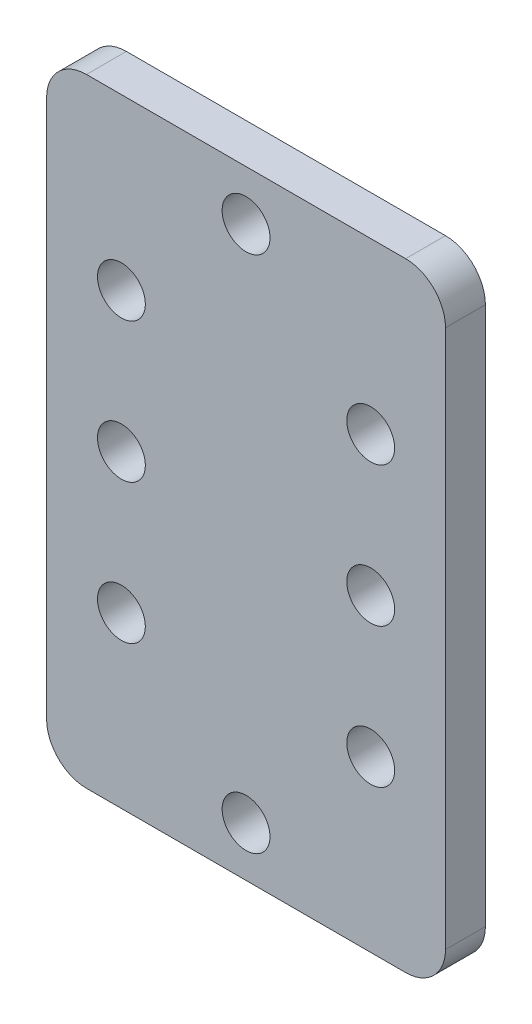
from build123d import *

# Parameters (mm, degrees)
SKETCH1_W           = 25.4
SKETCH1_H           = 39.37
SKETCH1_R           = 1.524
BOSS_EXTRUDE1_DEPTH = 2.54
FILLET1_R           = 2.54


with BuildPart() as part:
    # Sketch1 → Boss-Extrude1 (new body)
    with BuildSketch(Plane.XY):
        with Locations((12.7, -19.685)):
            Rectangle(SKETCH1_W, SKETCH1_H)
        with Locations((4.7625, -19.685)):
            Circle(SKETCH1_R, mode=Mode.SUBTRACT)
        with Locations((20.6375, -19.685)):
            Circle(SKETCH1_R, mode=Mode.SUBTRACT)
        with Locations((4.7625, -10.795)):
            Circle(SKETCH1_R, mode=Mode.SUBTRACT)
        with Locations((20.6375, -10.795)):
            Circle(SKETCH1_R, mode=Mode.SUBTRACT)
        with Locations((4.7625, -28.575)):
            Circle(SKETCH1_R, mode=Mode.SUBTRACT)
        with Locations((20.6375, -28.575)):
            Circle(SKETCH1_R, mode=Mode.SUBTRACT)
        with Locations((12.7, -3.175)):
            Circle(SKETCH1_R, mode=Mode.SUBTRACT)
        with Locations((12.7, -36.195)):
            Circle(SKETCH1_R, mode=Mode.SUBTRACT)
    extrude(amount=BOSS_EXTRUDE1_DEPTH)

    # Fillet1
    fillet1_edges = [part.edges().sort_by_distance(p)[0] for p in [
        (0, 0, 1.27),
        (25.4, 0, 1.27),
        (25.4, -39.37, 1.27),
        (0, -39.37, 1.27),
    ]]
    fillet(fillet1_edges, radius=FILLET1_R)


solid = part.part
